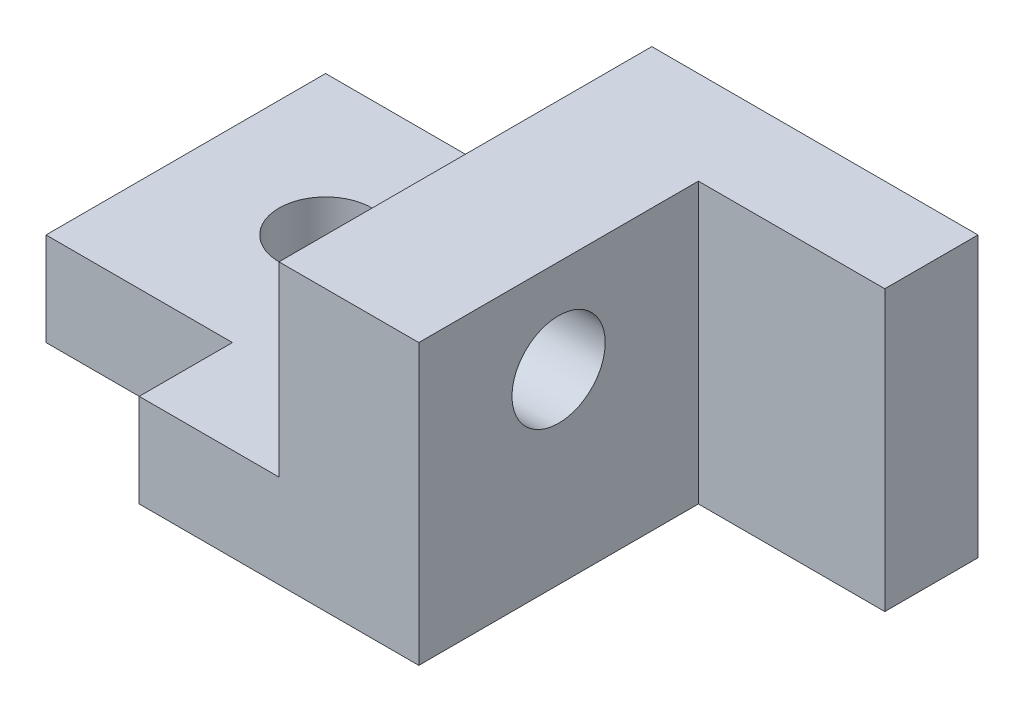
from build123d import *

# Parameters (mm, degrees)
SKETCH1_W               = 70
SKETCH1_H               = 40
BOSS_EXTRUDE1_DEPTH     = 30
SKETCH3_W               = 20
SKETCH3_H               = 30
CUT_EXTRUDE1_DEPTH      = 1
CUT_EXTRUDE1_DEPTH_BACK = 31
SKETCH4_W               = 35
SKETCH4_H               = 20
CUT_EXTRUDE2_DEPTH      = 41
SKETCH5_R               = 5
CUT_EXTRUDE3_DEPTH      = 30
SKETCH6_W               = 20
SKETCH6_H               = 10
CUT_EXTRUDE4_DEPTH      = 11
SKETCH7_R               = 5
CUT_EXTRUDE5_DEPTH      = 30


with BuildPart() as part:
    # Sketch1 → Boss-Extrude1 (new body)
    with BuildSketch(Plane(origin=(0, 0, 0), x_dir=(1, 0, 0), z_dir=(0, 1, 0))):
        with Locations((35, 20)):
            Rectangle(SKETCH1_W, SKETCH1_H)
    extrude(amount=BOSS_EXTRUDE1_DEPTH)

    # Sketch3 → Cut-Extrude1 (cut, two sides)
    with BuildSketch(Plane(origin=(0, 30, 0), x_dir=(1, 0, 0), z_dir=(0, 1, 0))) as cut_extrude1_sk:
        with Locations((60, 15)):
            Rectangle(SKETCH3_W, SKETCH3_H)
    extrude(amount=CUT_EXTRUDE1_DEPTH, mode=Mode.SUBTRACT)
    extrude(cut_extrude1_sk.sketch, amount=-CUT_EXTRUDE1_DEPTH_BACK, mode=Mode.SUBTRACT)

    # Sketch4 → Cut-Extrude2 (cut, through all)
    with BuildSketch(Plane.XY):
        with Locations((17.5, 20)):
            Rectangle(SKETCH4_W, SKETCH4_H)
    extrude(amount=-CUT_EXTRUDE2_DEPTH, mode=Mode.SUBTRACT)

    # Sketch5 → Cut-Extrude3 (cut)
    with BuildSketch(Plane(origin=(50, 0, 0), x_dir=(0, 0, -1), z_dir=(1, 0, 0))):
        with Locations((15, 20)):
            Circle(SKETCH5_R)
    extrude(amount=-CUT_EXTRUDE3_DEPTH, mode=Mode.SUBTRACT)

    # Sketch6 → Cut-Extrude4 (cut, through all)
    with BuildSketch(Plane(origin=(0, 10, 0), x_dir=(1, 0, 0), z_dir=(0, 1, 0))):
        with Locations((10, 5)):
            Rectangle(SKETCH6_W, SKETCH6_H)
    extrude(amount=-CUT_EXTRUDE4_DEPTH, mode=Mode.SUBTRACT)

    # Sketch7 → Cut-Extrude5 (cut)
    with BuildSketch(Plane(origin=(0, 10, 0), x_dir=(1, 0, 0), z_dir=(0, 1, 0))):
        with Locations((15, 25)):
            Circle(SKETCH7_R)
    extrude(amount=-CUT_EXTRUDE5_DEPTH, mode=Mode.SUBTRACT)


solid = part.part
